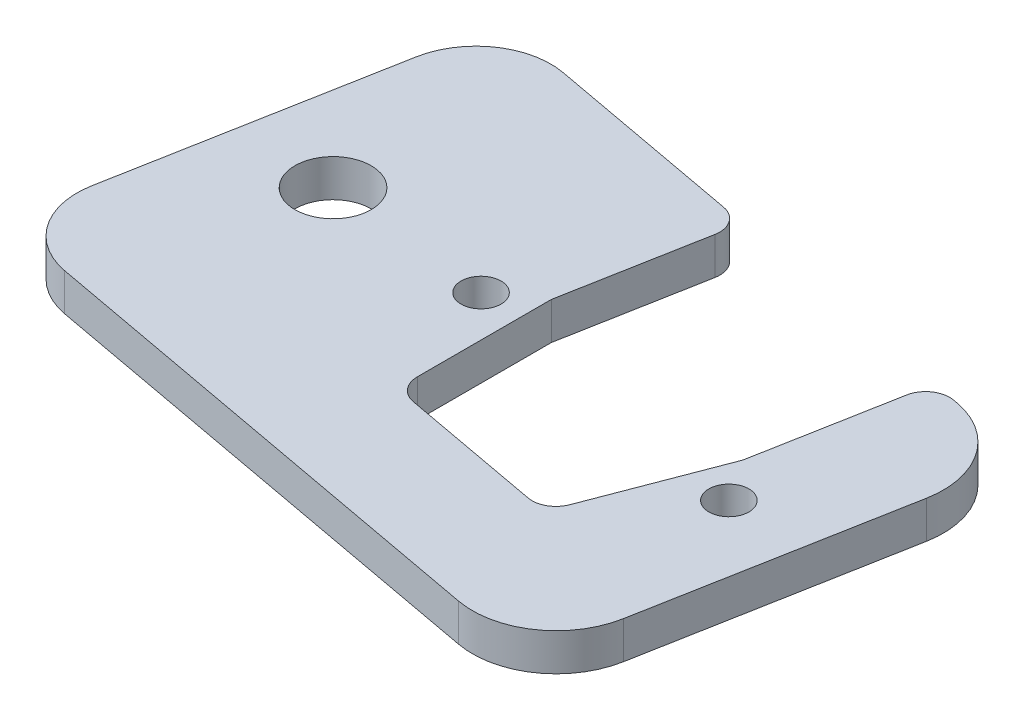
from build123d import *

# Parameters (mm, degrees)
SKETCH1_R           = 1.7018
SKETCH1_R_2         = 3.2385
BOSS_EXTRUDE1_DEPTH = 3.175


with BuildPart() as part:
    # Sketch1 → Boss-Extrude1 (new body)
    with BuildSketch(Plane(origin=(0, 0, 0), x_dir=(1, 0, 0), z_dir=(0, 1, 0))):
        with BuildLine():
            Line((-26.385767095, 2.692431218), (-9.650546347, -0.397020276))
            ThreePointArc((-9.650546347, -0.397020276), (-8.345625907, -1.243134279), (-8.021200765, -2.76414532))
            Line((-8.021200765, -2.76414532), (-10.188427932, -14.503777784))
            Line((-10.188427932, -14.503777784), (-10.188427932, -25.895050365))
            ThreePointArc((-10.188427932, -25.895050365), (-9.718255056, -27.194942681), (-8.525317662, -27.893285678))
            Line((-8.525317662, -27.893285678), (3.434770775, -30.101210727))
            ThreePointArc((3.434770775, -30.101210727), (4.798418745, -29.874833209), (5.701723859, -28.828495578))
            Line((5.701723859, -28.828495578), (9.768947258, -18.188063969))
            Line((9.768947258, -18.188063969), (11.936174425, -6.448431504))
            ThreePointArc((11.936174425, -6.448431504), (12.782288428, -5.143511064), (14.303299469, -4.819085921))
            Line((14.303299469, -4.819085921), (14.67796859, -4.888252746))
            ThreePointArc((14.67796859, -4.888252746), (19.245190129, -7.849651756), (20.380678129, -13.173190399))
            Line((20.380678129, -13.173190399), (16.362085627, -34.941466341))
            ThreePointArc((16.362085627, -34.941466341), (13.400686617, -39.50868788), (8.077147974, -40.64417588))
            Line((8.077147974, -40.64417588), (-32.986587711, -33.063491917))
            ThreePointArc((-32.986587711, -33.063491917), (-37.064464086, -30.419385658), (-38.078292657, -25.666226155))
            Line((-38.078292657, -25.666226155), (-33.783032856, -2.399273728))
            ThreePointArc((-33.783032856, -2.399273728), (-31.138926597, 1.678602647), (-26.385767095, 2.692431218))
        make_face()
        with Locations((12.145909657, -21.752201671)):
            Circle(SKETCH1_R, mode=Mode.SUBTRACT)
        with Locations((-13.681281765, -16.984301904)):
            Circle(SKETCH1_R, mode=Mode.SUBTRACT)
        with Locations((-27.68794209, -15.55442008)):
            Circle(SKETCH1_R_2, mode=Mode.SUBTRACT)
    extrude(amount=BOSS_EXTRUDE1_DEPTH)


solid = part.part
